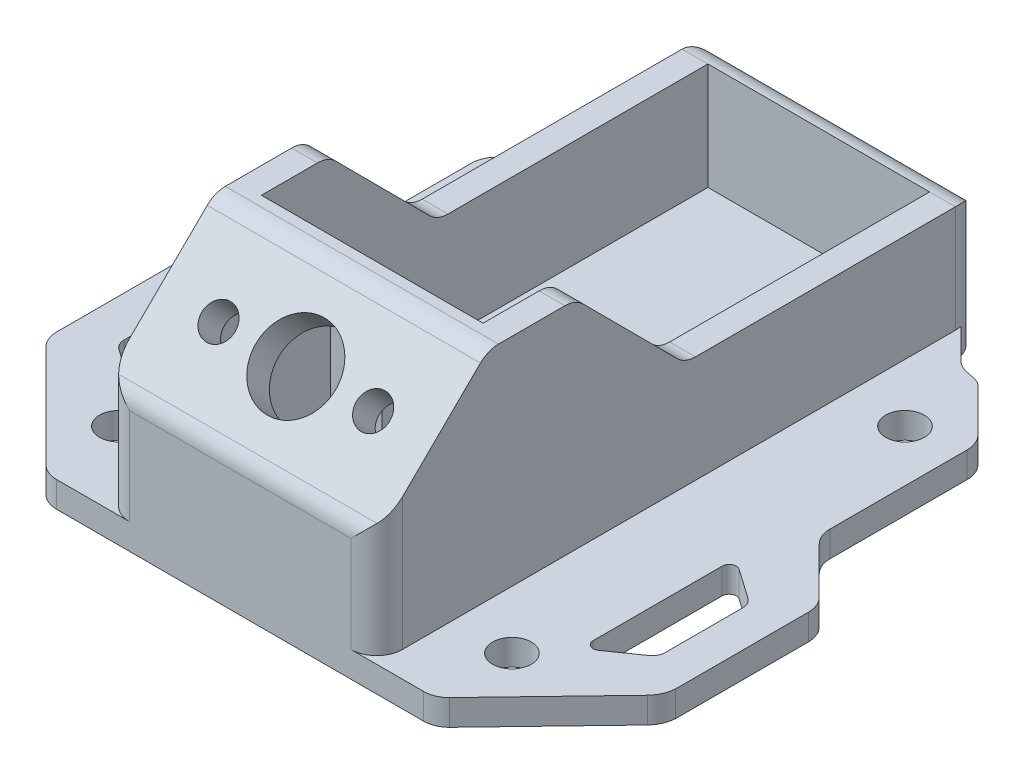
from build123d import *

# Parameters (mm, degrees)
BOSS_EXTRUDE1_DEPTH      = 2
SKETCH2_R                = 1.500000246
SKETCH2_R_2              = 1.5
CUT_EXTRUDE1_DEPTH       = 3
CUT_EXTRUDE3_DEPTH       = 3
SKETCH4_W                = 17.2
SKETCH4_H                = 42.900000423
BOSS_EXTRUDE2_DEPTH      = 16.8
BOSS_EXTRUDE2_DEPTH_BACK = 2
CUT_EXTRUDE4_DEPTH       = 35.442318281
BOSS_EXTRUDE3_REACH      = 34.758
CUT_EXTRUDE5_REACH       = 42.25
SKETCH7_R                = 3.1
SKETCH7_R_2              = 1.3
CUT_EXTRUDE6_REACH       = 4
SKETCH10_W               = 4
SKETCH10_H               = 2.4
BOSS_EXTRUDE4_DEPTH      = 8


with BuildPart() as part:
    # Sketch1 → Boss-Extrude1 (new body)
    with BuildSketch(Plane(origin=(0, 0, 0), x_dir=(1, 0, 0), z_dir=(0, 1, 0))):
        with BuildLine():
            Line((18.572356392, 15.455642083), (15.400781136, 18.627215476))
            ThreePointArc((15.400781136, 18.627215476), (15.000980559, 18.963075341), (14.510830812, 19.14306305))
            Line((14.510830812, 19.14306305), (13.829154841, 19.266075861))
            ThreePointArc((13.829154841, 19.266075861), (13.350450837, 19.465809152), (12.939209066, 19.781927984))
            Line((12.939209066, 19.781927984), (9.538270081, 23.182866969))
            ThreePointArc((9.538270081, 23.182866969), (9.061835297, 23.501210514), (8.499842151, 23.612997901))
            Line((8.499842151, 23.612997901), (-8.368205994, 23.612997901))
            ThreePointArc((-8.368205994, 23.612997901), (-9.221556491, 23.443255933), (-9.94499211, 22.959871707))
            Line((-9.94499211, 22.959871707), (-13.122935832, 19.781927984))
            ThreePointArc((-13.122935832, 19.781927984), (-13.53417801, 19.465808988), (-14.012882539, 19.266075861))
            Line((-14.012882539, 19.266075861), (-14.694557578, 19.14306305))
            ThreePointArc((-14.694557578, 19.14306305), (-15.184706626, 18.963073976), (-15.584504285, 18.627210927))
            Line((-15.584504285, 18.627210927), (-18.756076746, 15.455636602))
            ThreePointArc((-18.756076746, 15.455636602), (-19.189622668, 14.806788967), (-19.341863745, 14.041421099))
            Line((-19.341863745, 14.041421099), (-19.341863745, 3.384570997))
            ThreePointArc((-19.341863745, 3.384570997), (-19.494104434, 2.619205106), (-19.927649253, 1.970359158))
            Line((-19.927649253, 1.970359158), (-23.506077059, -1.608070511))
            ThreePointArc((-23.506077059, -1.608070511), (-23.939622981, -2.25691811), (-24.091864058, -3.022285948))
            Line((-24.091864058, -3.022285948), (-24.091864058, -13.36542942))
            ThreePointArc((-24.091864058, -13.36542942), (-23.939623268, -14.130795551), (-23.506078181, -14.779641628))
            Line((-23.506078181, -14.779641628), (-15.584504285, -22.701215524))
            ThreePointArc((-15.584504285, -22.701215524), (-14.935656966, -23.134761442), (-14.170289369, -23.287002522))
            Line((-14.170289369, -23.287002522), (14.301925526, -23.287002522))
            ThreePointArc((14.301925526, -23.287002522), (15.067293123, -23.134761442), (15.716140442, -22.701215524))
            Line((15.716140442, -22.701215524), (23.23794041, -14.862959876))
            ThreePointArc((23.23794041, -14.862959876), (23.709924747, -14.155388537), (23.90813636, -13.32826184))
            Line((23.90813636, -13.32826184), (23.90813636, -3.022286468))
            ThreePointArc((23.90813636, -3.022286468), (23.755895287, -2.25691839), (23.322349361, -1.608070511))
            Line((23.322349361, -1.608070511), (19.743924908, 1.970357668))
            ThreePointArc((19.743924908, 1.970357668), (19.310378982, 2.619205547), (19.158137909, 3.384573625))
            Line((19.158137909, 3.384573625), (19.158137909, 14.041440986))
            ThreePointArc((19.158137909, 14.041440986), (19.005898249, 14.806801151), (18.572356392, 15.455642083))
        make_face()
    extrude(amount=BOSS_EXTRUDE1_DEPTH)

    # Sketch2 → Cut-Extrude1 (cut, through all)
    with BuildSketch(Plane(origin=(0, 2, 0), x_dir=(1, 0, 0), z_dir=(0, 1, 0))):
        with Locations((-15.341864952, -17.28700247)):
            Circle(SKETCH2_R)
        with Locations((15.158137254, -17.28700247)):
            Circle(SKETCH2_R)
        with Locations((15.158137909, 13.212998804)):
            Circle(SKETCH2_R_2)
        with Locations((-15.341866539, 13.212998804)):
            Circle(SKETCH2_R_2)
    extrude(amount=-CUT_EXTRUDE1_DEPTH, mode=Mode.SUBTRACT)

    # Sketch3 → Cut-Extrude3 (cut, through all)
    with BuildSketch(Plane.XZ):
        with BuildLine():
            Line((18.332290758, 13.738059649), (20.625916482, 12.132045627))
            ThreePointArc((20.625916482, 12.132045627), (20.949257646, 11.763345693), (21.065818079, 11.287002522))
            Line((21.065818079, 11.287002522), (21.065818079, 5.287002522))
            ThreePointArc((21.065818079, 5.287002522), (20.949257646, 4.810659352), (20.625916482, 4.441959417))
            Line((20.625916482, 4.441959417), (18.332290758, 2.835945395))
            ThreePointArc((18.332290758, 2.835945395), (17.762200326, 2.798579694), (17.465818079, 3.287002522))
            Line((17.465818079, 3.287002522), (17.465818079, 13.287002522))
            ThreePointArc((17.465818079, 13.287002522), (17.762200326, 13.77542535), (18.332290758, 13.738059649))
        make_face()
        with BuildLine():
            Line((-17.334181921, 13.287002522), (-17.334181921, 3.287002522))
            ThreePointArc((-17.334181921, 3.287002522), (-17.630564169, 2.798579694), (-18.200654601, 2.835945395))
            Line((-18.200654601, 2.835945395), (-20.494280325, 4.441959417))
            ThreePointArc((-20.494280325, 4.441959417), (-20.817621489, 4.810659352), (-20.934181921, 5.287002522))
            Line((-20.934181921, 5.287002522), (-20.934181921, 11.287002522))
            ThreePointArc((-20.934181921, 11.287002522), (-20.817621489, 11.763345693), (-20.494280325, 12.132045627))
            Line((-20.494280325, 12.132045627), (-18.200654601, 13.738059649))
            ThreePointArc((-18.200654601, 13.738059649), (-17.630564169, 13.77542535), (-17.334181921, 13.287002522))
        make_face()
    extrude(amount=-CUT_EXTRUDE3_DEPTH, mode=Mode.SUBTRACT)

    # Sketch4 → Boss-Extrude2 (add, two sides)
    with BuildSketch(Plane(origin=(0, 2, 0), x_dir=(1, 0, 0), z_dir=(0, 1, 0))) as boss_extrude2_sk:
        with BuildLine():
            Line((-8.534181921, -23.287002522), (8.665818079, -23.287002522))
            ThreePointArc((8.665818079, -23.287002522), (10.080031641, -22.701216085), (10.665818079, -21.287002522))
            Line((10.665818079, -21.287002522), (10.665818079, 21.612997901))
            ThreePointArc((10.665818079, 21.612997901), (10.080031641, 23.027211463), (8.665818079, 23.612997901))
            Line((8.665818079, 23.612997901), (-8.534181921, 23.612997901))
            ThreePointArc((-8.534181921, 23.612997901), (-9.948395484, 23.027211463), (-10.534181921, 21.612997901))
            Line((-10.534181921, 21.612997901), (-10.534181921, -21.287002522))
            ThreePointArc((-10.534181921, -21.287002522), (-9.948395484, -22.701216085), (-8.534181921, -23.287002522))
        make_face()
        with Locations((0.065818079, 0.162997689)):
            Rectangle(SKETCH4_W, SKETCH4_H, mode=Mode.SUBTRACT)
    extrude(amount=BOSS_EXTRUDE2_DEPTH)
    extrude(boss_extrude2_sk.sketch, amount=-BOSS_EXTRUDE2_DEPTH_BACK)

    # Sketch5 → Cut-Extrude4 (cut, through all)
    with BuildSketch(Plane.ZY.offset(10.534181921)):
        with BuildLine():
            Line((-21.612997901, 10.3), (-1.443459743, 10.3))
            ThreePointArc((-1.443459743, 10.3), (-0.676489206, 10.452906013), (-0.026793076, 10.888243804))
            Line((-0.026793076, 10.888243804), (7.271334447, 18.211756196))
            ThreePointArc((7.271334447, 18.211756196), (7.921030577, 18.647093987), (8.688001114, 18.8))
            Line((8.688001114, 18.8), (13.837952846, 18.8))
            ThreePointArc((13.837952846, 18.8), (14.596331781, 18.650638104), (15.2414378, 18.224861392))
            Line((15.2414378, 18.224861392), (22.690487476, 10.887565848))
            ThreePointArc((22.690487476, 10.887565848), (23.131856162, 10.235048322), (23.287002522, 9.462704457))
            Line((23.287002522, 9.462704457), (23.287002522, 6.883402598))
            Line((23.287002522, 6.883402598), (26.098263888, 6.883402598))
            Line((26.098263888, 6.883402598), (26.098263888, 23.771252442))
            Line((26.098263888, 23.771252442), (-26.157105029, 23.771252442))
            Line((-26.157105029, 23.771252442), (-26.157105029, 6.5400194))
            Line((-26.157105029, 6.5400194), (-23.612997901, 6.5400194))
            Line((-23.612997901, 6.5400194), (-23.612997901, 8.3))
            ThreePointArc((-23.612997901, 8.3), (-23.027211463, 9.714213562), (-21.612997901, 10.3))
        make_face()
    extrude(amount=-CUT_EXTRUDE4_DEPTH, mode=Mode.SUBTRACT)

    # Sketch6 → Boss-Extrude3 (add, up to next)
    with BuildSketch(Plane.ZY.offset(-8.665818079), mode=Mode.PRIVATE) as boss_extrude3_sk1:
        with BuildLine():
            Line((21.287002522, 12.269995063), (15.2414378, 18.224861392))
            ThreePointArc((15.2414378, 18.224861392), (14.596331781, 18.650638104), (13.837952846, 18.8))
            Line((13.837952846, 18.8), (13.034792435, 18.8))
            Line((13.034792435, 18.8), (13.034792435, 16.889288371))
            Line((13.034792435, 16.889288371), (21.313555812, 8.73472688))
            Line((21.313555812, 8.73472688), (23.287002522, 8.73472688))
            Line((23.287002522, 8.73472688), (23.287002522, 9.462704457))
            ThreePointArc((23.287002522, 9.462704457), (23.131856162, 10.235048322), (22.690487476, 10.887565848))
            Line((22.690487476, 10.887565848), (21.287002522, 12.269995063))
        make_face()
    boss_extrude3_tool1 = extrude(boss_extrude3_sk1.sketch, amount=BOSS_EXTRUDE3_REACH, mode=Mode.PRIVATE) - part.part
    add(boss_extrude3_tool1.solids().sort_by_distance((8.665818, 13.686528, 18.07587))[0])

    # Sketch7 → Cut-Extrude5 (cut, up to next)
    with BuildSketch(Plane(origin=(0, 16.870013343, 16.6169215), x_dir=(1, 0, 0), z_dir=(0, 0.712430696, 0.701742477)), mode=Mode.PRIVATE) as cut_extrude5_sk1:
        with Locations((0.065818079, -3.297220561)):
            Circle(SKETCH7_R)
    cut_extrude5_tool1 = extrude(cut_extrude5_sk1.sketch, amount=-CUT_EXTRUDE5_REACH, mode=Mode.PRIVATE) & part.part
    add(cut_extrude5_tool1.solids().sort_by_distance((0.065818, 14.556214, 18.965963))[0], mode=Mode.SUBTRACT)
    # Sketch7 → Cut-Extrude5 (cut, up to next)
    with BuildSketch(Plane(origin=(0, 16.870013343, 16.6169215), x_dir=(1, 0, 0), z_dir=(0, 0.712430696, 0.701742477)), mode=Mode.PRIVATE) as cut_extrude5_sk2:
        with Locations((6.065818079, -3.297220561)):
            Circle(SKETCH7_R_2)
    cut_extrude5_tool2 = extrude(cut_extrude5_sk2.sketch, amount=-CUT_EXTRUDE5_REACH, mode=Mode.PRIVATE) & part.part
    add(cut_extrude5_tool2.solids().sort_by_distance((6.065818, 14.556214, 18.965963))[0], mode=Mode.SUBTRACT)
    # Sketch7 → Cut-Extrude5 (cut, up to next)
    with BuildSketch(Plane(origin=(0, 16.870013343, 16.6169215), x_dir=(1, 0, 0), z_dir=(0, 0.712430696, 0.701742477)), mode=Mode.PRIVATE) as cut_extrude5_sk3:
        with Locations((-5.934181921, -3.297220561)):
            Circle(SKETCH7_R_2)
    cut_extrude5_tool3 = extrude(cut_extrude5_sk3.sketch, amount=-CUT_EXTRUDE5_REACH, mode=Mode.PRIVATE) & part.part
    add(cut_extrude5_tool3.solids().sort_by_distance((-5.934182, 14.556214, 18.965963))[0], mode=Mode.SUBTRACT)

    # Sketch9 → Cut-Extrude6 (cut, up to next)
    with BuildSketch(Plane(origin=(0, 2, 0), x_dir=(1, 0, 0), z_dir=(0, 1, 0)), mode=Mode.PRIVATE) as cut_extrude6_sk1:
        Polygon((-8.534181921, -21.287002522), (8.665818079, -21.287002522), (8.665818079, -7.687002522), (4.665818079, -7.687002522), (4.665818079, -2.492093964), (-4.534181921, -2.492093964), (-4.534181921, -7.687002522), (-8.534181921, -7.687002522), align=None)
    cut_extrude6_tool1 = extrude(cut_extrude6_sk1.sketch, amount=-CUT_EXTRUDE6_REACH, mode=Mode.PRIVATE) & part.part
    add(cut_extrude6_tool1.solids().sort_by_distance((0.065818, 2, 12.892707))[0], mode=Mode.SUBTRACT)

    # Sketch10 → Boss-Extrude4 (add)
    with BuildSketch(Plane(origin=(0, 2, 0), x_dir=(1, 0, 0), z_dir=(0, 1, 0))):
        with Locations((6.665818079, -6.487002522)):
            Rectangle(SKETCH10_W, SKETCH10_H)
        with Locations((-6.534181921, -6.487002522)):
            Rectangle(SKETCH10_W, SKETCH10_H)
    extrude(amount=BOSS_EXTRUDE4_DEPTH)


solid = part.part
